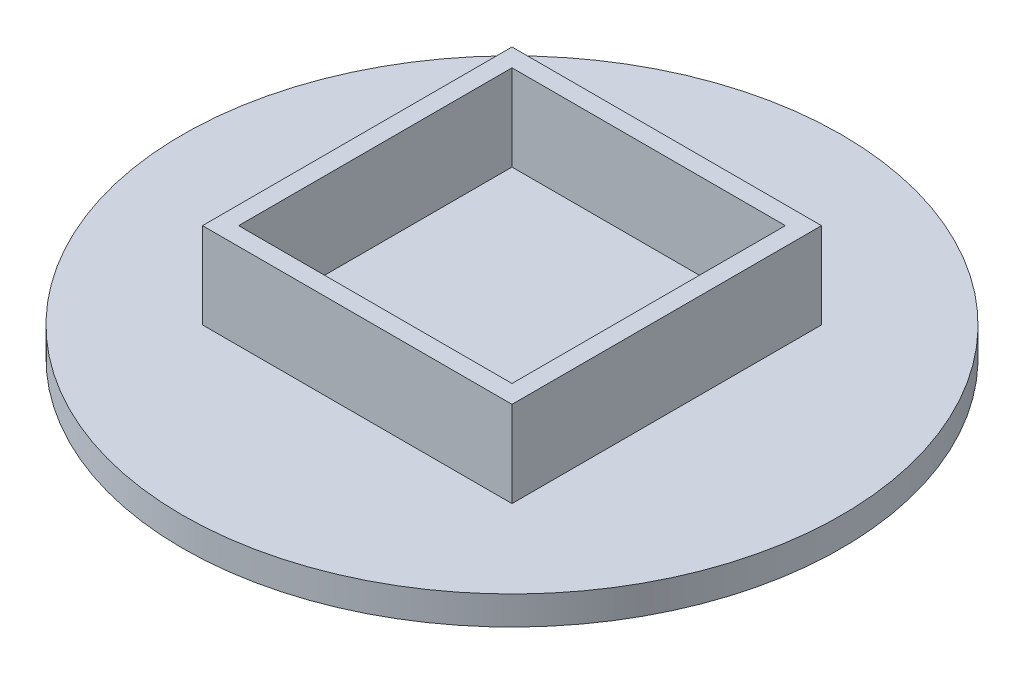
from build123d import *

# Parameters (mm, degrees)
SKETCH1_W           = 68.58
SKETCH1_H           = 68.58
SKETCH1_W_2         = 60.58
SKETCH1_H_2         = 60.58
BOSS_EXTRUDE1_DEPTH = 25.4
SKETCH2_R           = 73.025
BOSS_EXTRUDE2_DEPTH = 6.35


with BuildPart() as part:
    # Sketch1 → Boss-Extrude1 (new body)
    with BuildSketch(Plane(origin=(0, 0, 0), x_dir=(1, 0, 0), z_dir=(0, 1, 0))):
        Rectangle(SKETCH1_W, SKETCH1_H)
        Rectangle(SKETCH1_W_2, SKETCH1_H_2, mode=Mode.SUBTRACT)
    extrude(amount=BOSS_EXTRUDE1_DEPTH)

    # Sketch2 → Boss-Extrude2 (add)
    with BuildSketch(Plane(origin=(0, 0, 0), x_dir=(1, 0, 0), z_dir=(0, 1, 0))):
        Circle(SKETCH2_R)
    extrude(amount=BOSS_EXTRUDE2_DEPTH)


solid = part.part
